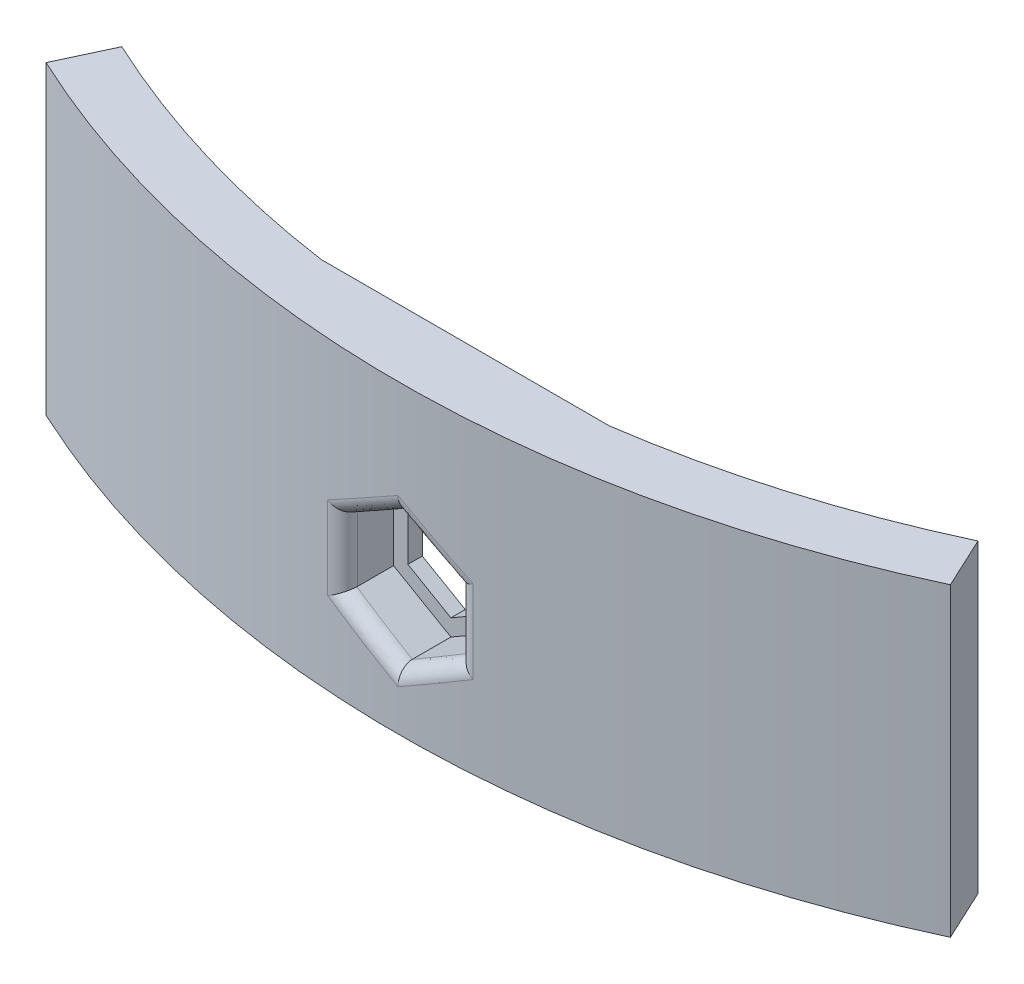
from build123d import *

# Parameters (mm, degrees)
SKETCH1_W                    = 25.4
SKETCH1_H                    = 21.844
BOLT_SIZE_WIDTH_HEIGHT_DEPTH = 7.62
FRONT_CURVE_DEPTH            = 22.844
SKETCH3_W                    = 25.4
SKETCH3_H                    = 21.844
REAR_CAP_DEPTH               = 1.27
WINGS_DEPTH                  = 21.844
HOOK_DEPTH_DEPTH             = 5.08
HOOK_HEIGHT_DEPTH            = 3.81
NUT_FLANGE_CLEARANCE_R       = 1.27
DECORATION_SIZE              = 2.54
CUT_EXTRUDE1_DEPTH           = 27.9240001


with BuildPart() as part:
    # Sketch1 → Bolt Size, Width, &Height (new body)
    with BuildSketch(Plane.XY):
        Rectangle(SKETCH1_W, SKETCH1_H)
        Polygon((0, 5.842), (-5.059320409, 2.921), (-5.059320409, -2.921), (0, -5.842), (5.059320409, -2.921), (5.059320409, 2.921), align=None, mode=Mode.SUBTRACT)
    extrude(amount=BOLT_SIZE_WIDTH_HEIGHT_DEPTH)

    # Sketch2 → Front Curve (cut, through all)
    with BuildSketch(Plane(origin=(0, 10.922, 0), x_dir=(1, 0, 0), z_dir=(0, 1, 0))):
        with BuildLine():
            Line((12.7, -7.62), (12.7, -3.81))
            ThreePointArc((12.7, -3.81), (0, -4.668549118), (-12.7, -3.81))
            Line((-12.7, -3.81), (-12.7, -7.62))
            Line((-12.7, -7.62), (12.7, -7.62))
        make_face()
    extrude(amount=-FRONT_CURVE_DEPTH, mode=Mode.SUBTRACT)

    # Sketch3 → Rear Cap (add)
    with BuildSketch(Plane(origin=(0, 0, 0), x_dir=(-1, 0, 0), z_dir=(0, 0, -1))):
        Rectangle(SKETCH3_W, SKETCH3_H)
        Polygon((-3.789320409, 2.187765158), (-3.789320409, -2.187765158), (0, -4.375530316), (3.789320409, -2.187765158), (3.789320409, 2.187765158), (0, 4.375530316), align=None, mode=Mode.SUBTRACT)
    extrude(amount=REAR_CAP_DEPTH)

    # Sketch6 → Wings (add)
    with BuildSketch(Plane.XZ.offset(10.922)):
        with BuildLine():
            ThreePointArc((-12.7, 3.81), (-26.59057897, 0.844499757), (-39.878681796, -4.17234179))
            Line((-39.878681796, -4.17234179), (-37.752420533, -8.732123784))
            ThreePointArc((-37.752420533, -8.732123784), (-25.500637389, -4.079733878), (-12.7, -1.27))
            Line((-12.7, -1.27), (-12.7, 3.81))
        make_face()
        with BuildLine():
            ThreePointArc((39.878681796, -4.17234179), (26.59057897, 0.844499757), (12.7, 3.81))
            Line((12.7, 3.81), (12.7, -1.27))
            ThreePointArc((12.7, -1.27), (25.500637389, -4.079733878), (37.752420533, -8.732123784))
            Line((37.752420533, -8.732123784), (39.878681796, -4.17234179))
        make_face()
    extrude(amount=-WINGS_DEPTH)

    # Sketch7 → Hook Depth (add)
    with BuildSketch(Plane(origin=(0, 10.922, 0), x_dir=(1, 0, 0), z_dir=(0, 1, 0))):
        with BuildLine():
            Line((12.7, 1.27), (-12.7, 1.27))
            ThreePointArc((-12.7, 1.27), (-25.500637389, 4.079733878), (-37.752420533, 8.732123784))
            Line((-37.752420533, 8.732123784), (-42.90498238, -2.317580756))
            ThreePointArc((-42.90498238, -2.317580756), (-31.916762044, -6.681838924), (-20.495660276, -9.738989543))
            Line((-20.495660276, -9.738989543), (-19.05, -2.725598334))
            ThreePointArc((-19.05, -2.725598334), (0, -4.668549118), (19.05, -2.725598334))
            Line((19.05, -2.725598334), (20.495660276, -9.738989543))
            ThreePointArc((20.495660276, -9.738989543), (31.916762044, -6.681838924), (42.90498238, -2.317580756))
            Line((42.90498238, -2.317580756), (37.752420533, 8.732123784))
            ThreePointArc((37.752420533, 8.732123784), (25.500637389, 4.079733878), (12.7, 1.27))
        make_face()
    extrude(amount=HOOK_DEPTH_DEPTH)

    # Sketch8 → Hook Height (add)
    with BuildSketch(Plane.XZ.offset(-10.922)):
        with BuildLine():
            ThreePointArc((-20.495660276, 9.738989543), (-31.916762044, 6.681838924), (-42.90498238, 2.317580756))
            Line((-42.90498238, 2.317580756), (-41.831531995, 0.015558977))
            ThreePointArc((-41.831531995, 0.015558977), (-31.118228667, 4.270626689), (-19.982874273, 7.251289698))
            Line((-19.982874273, 7.251289698), (-20.495660276, 9.738989543))
        make_face()
        with BuildLine():
            Line((41.831531995, 0.015558977), (42.90498238, 2.317580756))
            ThreePointArc((42.90498238, 2.317580756), (31.916762044, 6.681838924), (20.495660276, 9.738989543))
            Line((20.495660276, 9.738989543), (19.982874273, 7.251289698))
            ThreePointArc((19.982874273, 7.251289698), (31.118228667, 4.270626689), (41.831531995, 0.015558977))
        make_face()
    extrude(amount=HOOK_HEIGHT_DEPTH)

    # Nut Flange Clearance
    nut_flange_clearance_edges = [part.edges().sort_by_distance(p)[0] for p in [
        (5.059320409, 0, 4.532819603),
        (2.530342979, 4.3811058, 4.634616736),
        (-2.530342979, 4.3811058, 4.634616736),
        (-5.059320409, 0, 4.532819603),
        (-2.530342979, -4.3811058, 4.634616736),
        (2.530342979, -4.3811058, 4.634616736),
    ]]
    fillet(nut_flange_clearance_edges, radius=NUT_FLANGE_CLEARANCE_R)

    # Decoration
    decoration_edges = [part.edges().sort_by_distance(p)[0] for p in [
        (-42.368257188, 7.112, 1.166569866),
        (-20.239267274, 7.112, 8.49513962),
        (42.368257188, 7.112, 1.166569866),
        (20.239267274, 7.112, 8.49513962),
    ]]
    chamfer(decoration_edges, length=DECORATION_SIZE)

    # Sketch9 → Cut-Extrude1 (cut, through all)
    with BuildSketch(Plane(origin=(0, 16.002, 0), x_dir=(1, 0, 0), z_dir=(0, 1, 0))):
        with BuildLine():
            Line((42.90498238, -2.317580756), (39.878681796, 4.17234179))
            ThreePointArc((39.878681796, 4.17234179), (0, -4.668549118), (-39.878681796, 4.17234179))
            Line((-39.878681796, 4.17234179), (-42.90498238, -2.317580756))
            ThreePointArc((-42.90498238, -2.317580756), (0, -11.82938635), (42.90498238, -2.317580756))
        make_face()
    extrude(amount=-CUT_EXTRUDE1_DEPTH, mode=Mode.SUBTRACT)


solid = part.part
